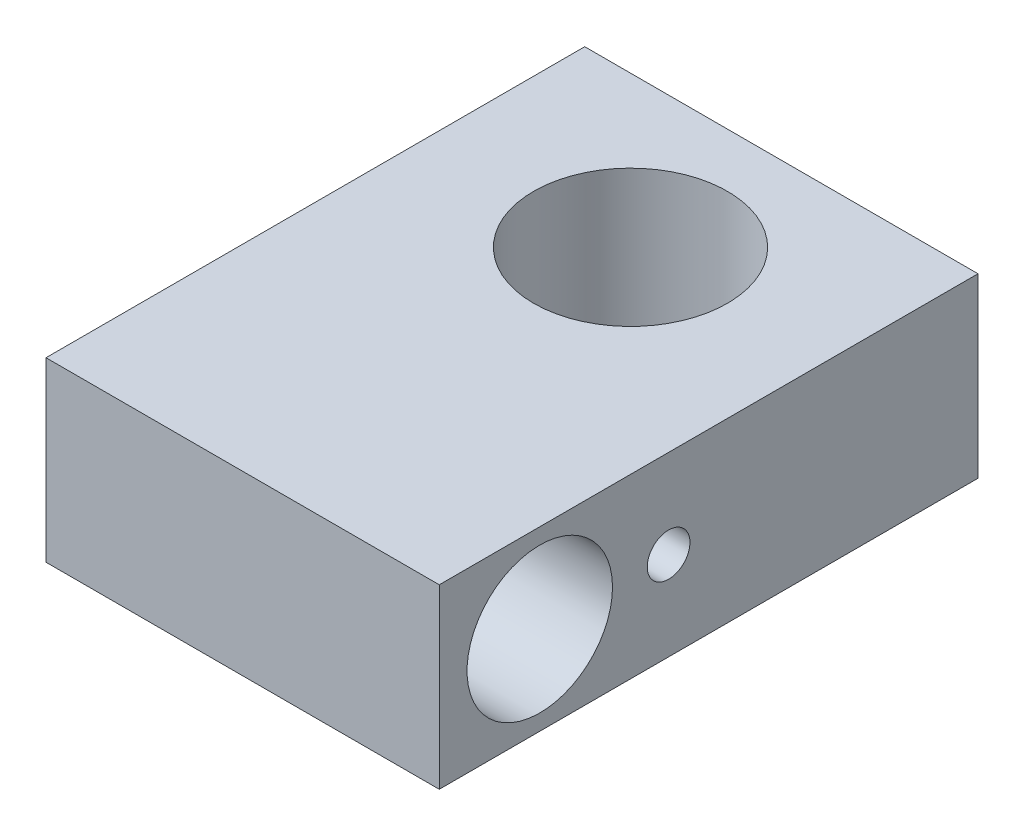
from build123d import *

# Parameters (mm, degrees)
SKETCH1_W              = 18.25
SKETCH1_H              = 25
BOSS_EXTRUDE1_DEPTH    = 8.22
M10X1_0_TAPPED_HOLE1_D = 9
SKETCH7_R              = 3.375
SKETCH7_R_2            = 0.9906
CUT_EXTRUDE2_DEPTH     = 19.25


with BuildPart() as part:
    # Sketch1 → Boss-Extrude1 (new body)
    with BuildSketch(Plane(origin=(0, 0, 0), x_dir=(1, 0, 0), z_dir=(0, 1, 0))):
        with Locations((0, -5.5)):
            Rectangle(SKETCH1_W, SKETCH1_H)
    extrude(amount=BOSS_EXTRUDE1_DEPTH)

    # M10x1.0 Tapped Hole1 (through all)
    with Locations(Plane(origin=(0, 8.22, 0), x_dir=(-1, 0, 0), z_dir=(0, 1, 0))):
        with Locations((0, 0)):
            Hole(M10X1_0_TAPPED_HOLE1_D / 2)

    # Sketch7 → Cut-Extrude2 (cut, through all)
    with BuildSketch(Plane(origin=(9.125, 0, 0), x_dir=(0, 0, -1), z_dir=(1, 0, 0))):
        with Locations((-13.336186812, 4.11)):
            Circle(SKETCH7_R)
        with Locations((-7.3575, 4.11)):
            Circle(SKETCH7_R_2)
    extrude(amount=-CUT_EXTRUDE2_DEPTH, mode=Mode.SUBTRACT)


solid = part.part
